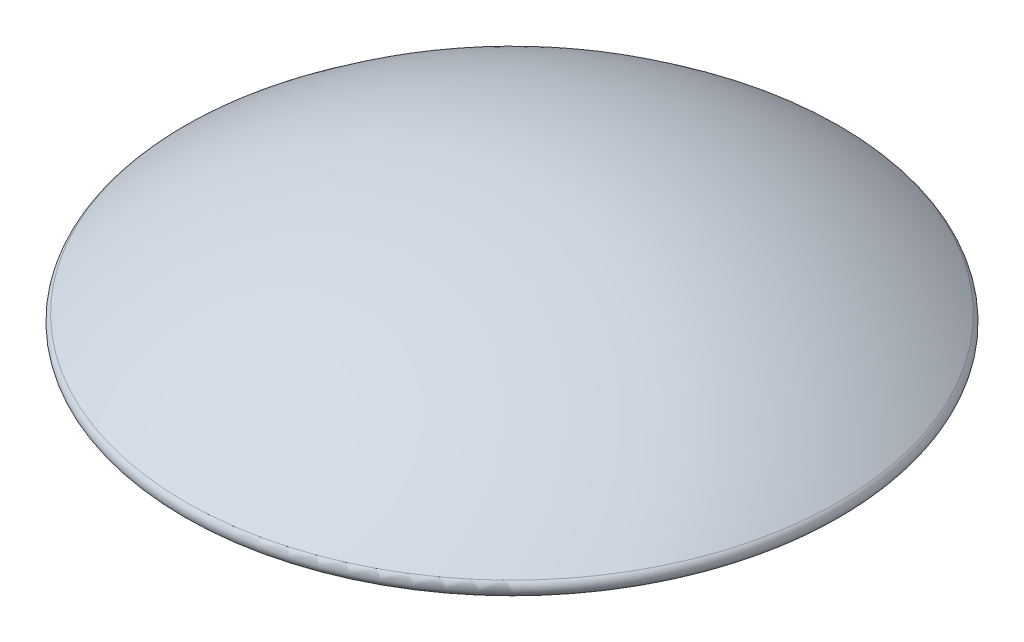
from build123d import *

# Parameters (mm, degrees)
VERRUNDUNG1_R = 0.2
FASE1_SIZE    = 0.2


with BuildPart() as part:
    # Skizze1 → Rotation1 (revolve)
    with BuildSketch(Plane(origin=(0, 0, 0), x_dir=(0, 0, -1), z_dir=(1, 0, 0))):
        with BuildLine():
            Line((-8, 0), (-5, 0))
            Line((-5, 0), (-5, -1))
            Line((-5, -1), (-4, -1))
            Line((-4, -1), (-4, 0))
            Line((-4, 0), (0, 0))
            Line((0, 0), (0, 3))
            ThreePointArc((0, 3), (-4.272001873, 2.225338327), (-8, 0))
        make_face()
    revolve(axis=Axis((0, 12.065472466, 0), (0, -1, 0)))

    # Verrundung1
    verrundung1_edges = [part.edges().sort_by_distance(p)[0] for p in [
        (0, 0, -8),
    ]]
    fillet(verrundung1_edges, radius=VERRUNDUNG1_R)

    # Fase1
    fase1_edges = [part.edges().sort_by_distance(p)[0] for p in [
        (0, 0, -5),
        (0, 0, -4),
        (0, -1, -5),
        (0, -1, -4),
    ]]
    chamfer(fase1_edges, length=FASE1_SIZE)


solid = part.part
